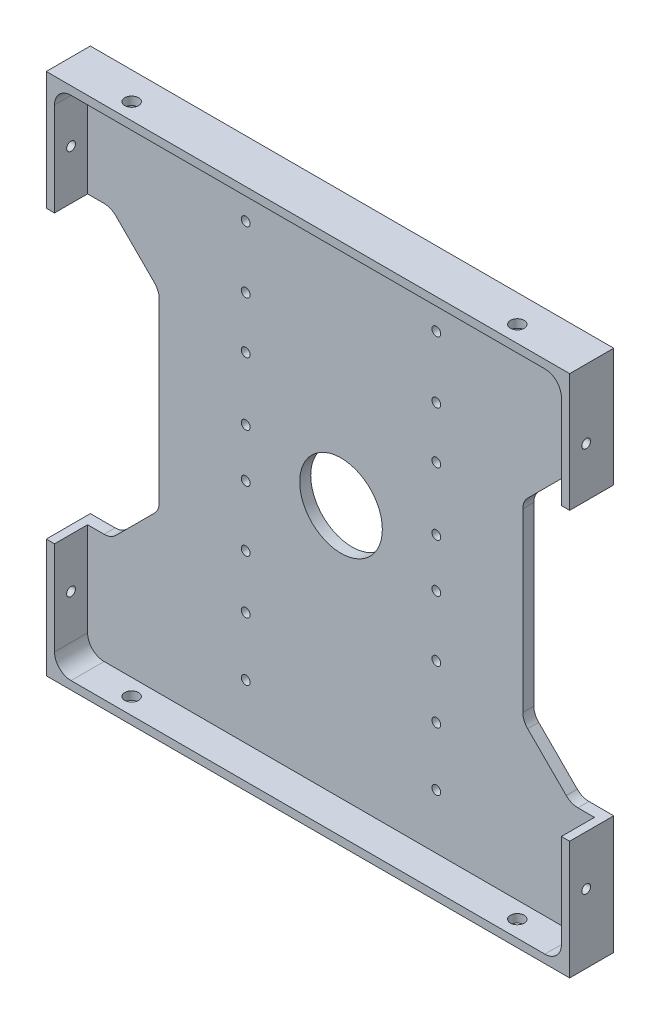
from build123d import *

# Parameters (mm, degrees)
SKETCH1_W                       = 96
SKETCH1_H                       = 96
BOSS_EXTRUDE1_DEPTH             = 8
SKETCH2_W                       = 92
SKETCH2_H                       = 92
COMPONENT_PLATFORM_DEPTH        = 6
CABLE_SLOTS_DEPTH               = 6
SKETCH4_R                       = 7.5
CENTER_MASS_CUT_DEPTH           = 6
INNER_CORNER_FILLETS_R          = 3
TAP_DRILL_FOR_M3X0_5_TAP4_D     = 2.5
TAP_DRILL_FOR_M3X0_5_TAP4_DEPTH = 2
TAP_DRILL_FOR_M2X0_4_TAP2_D     = 1.6
TAP_DRILL_FOR_M2X0_4_TAP1_D     = 1.6
TAP_DRILL_FOR_M2X0_4_TAP1_DEPTH = 2
CUT_EXTRUDE1_START              = -8
SKETCH28_OUTSIDE_W              = 125.2
SKETCH28_OUTSIDE_H              = 125.2
SKETCH28_OUTSIDE_W_2            = 95
SKETCH28_OUTSIDE_H_2            = 95
CUT_EXTRUDE1_DEPTH              = 8


with BuildPart() as part:
    # Sketch1 → Boss-Extrude1 (new body)
    with BuildSketch(Plane.XY):
        Rectangle(SKETCH1_W, SKETCH1_H)
    extrude(amount=BOSS_EXTRUDE1_DEPTH)

    # Sketch2 → Component Platform (cut)
    with BuildSketch(Plane.XY.offset(8)):
        Rectangle(SKETCH2_W, SKETCH2_H)
    extrude(amount=-COMPONENT_PLATFORM_DEPTH, mode=Mode.SUBTRACT)

    # Sketch3 → Cable Slots (cut, symmetric)
    with BuildSketch(Plane.XY.offset(2)):
        with BuildLine():
            Line((-40.878679656, -25.121320344), (-33.878679656, -18.121320344))
            ThreePointArc((-33.878679656, -18.121320344), (-33.228361402, -17.148050297), (-33, -16))
            Line((-33, -16), (-33, 16))
            ThreePointArc((-33, 16), (-33.228361402, 17.148050297), (-33.878679656, 18.121320344))
            Line((-33.878679656, 18.121320344), (-40.878679656, 25.121320344))
            ThreePointArc((-40.878679656, 25.121320344), (-41.851949703, 25.771638598), (-43, 26))
            Line((-43, 26), (-48, 26))
            Line((-48, 26), (-48, -26))
            Line((-48, -26), (-43, -26))
            ThreePointArc((-43, -26), (-41.851949703, -25.771638598), (-40.878679656, -25.121320344))
        make_face()
        with BuildLine():
            Line((48, -26), (48, 26))
            Line((48, 26), (43, 26))
            ThreePointArc((43, 26), (41.851949703, 25.771638598), (40.878679656, 25.121320344))
            Line((40.878679656, 25.121320344), (33.878679656, 18.121320344))
            ThreePointArc((33.878679656, 18.121320344), (33.228361402, 17.148050297), (33, 16))
            Line((33, 16), (33, -16))
            ThreePointArc((33, -16), (33.228361402, -17.148050297), (33.878679656, -18.121320344))
            Line((33.878679656, -18.121320344), (40.878679656, -25.121320344))
            ThreePointArc((40.878679656, -25.121320344), (41.851949703, -25.771638598), (43, -26))
            Line((43, -26), (48, -26))
        make_face()
    extrude(amount=CABLE_SLOTS_DEPTH, both=True, mode=Mode.SUBTRACT)

    # Sketch4 → Center Mass Cut (cut)
    with BuildSketch(Plane.XY.offset(2)):
        Circle(SKETCH4_R)
    extrude(amount=-CENTER_MASS_CUT_DEPTH, mode=Mode.SUBTRACT)

    # Inner Corner Fillets
    inner_corner_fillets_edges = [part.edges().sort_by_distance(p)[0] for p in [
        (-46, -46, 5),
        (-46, 46, 5),
        (46, 46, 5),
        (46, -46, 5),
    ]]
    fillet(inner_corner_fillets_edges, radius=INNER_CORNER_FILLETS_R)

    # Tap Drill for M3x0.5 Tap4
    with Locations(Plane(origin=(0, -48, 0), x_dir=(-1, 0, 0), z_dir=(0, -1, 0))):
        with Locations((35, -5), (-35, -5)):
            tap_drill_for_m3x0_5_tap4 = Hole(TAP_DRILL_FOR_M3X0_5_TAP4_D / 2, depth=TAP_DRILL_FOR_M3X0_5_TAP4_DEPTH)

    # Mirror2: Tap Drill for M3x0.5 Tap4 across plane
    add(tap_drill_for_m3x0_5_tap4.mirror(Plane(origin=(0, 0, 0), x_dir=(0, 0, 1), z_dir=(0, -1, 0))), mode=Mode.SUBTRACT)

    # Tap Drill for M2x0.4 Tap2 (through all)
    with Locations(Plane.XY.offset(2)):
        with Locations((-17.3, 36.05), (-17.3, 24.85), (-17.3, 15.45), (-17.3, 4.05), (17.3, 4.05), (17.3, 15.45), (17.3, 24.85), (17.3, 36.05), (17.3, -4.75), (17.3, -15.75), (17.3, -25.45), (17.3, -36.05), (-17.3, -4.75), (-17.3, -15.75), (-17.3, -25.45), (-17.3, -36.05)):
            Hole(TAP_DRILL_FOR_M2X0_4_TAP2_D / 2)

    # Tap Drill for M2x0.4 Tap1
    with Locations(Plane(origin=(48, 0, 0), x_dir=(0, 0, -1), z_dir=(1, 0, 0))):
        with Locations((-5, -35), (-5, 35)):
            tap_drill_for_m2x0_4_tap1 = Hole(TAP_DRILL_FOR_M2X0_4_TAP1_D / 2, depth=TAP_DRILL_FOR_M2X0_4_TAP1_DEPTH)

    # Mirror3: Tap Drill for M2x0.4 Tap1 across plane
    add(tap_drill_for_m2x0_4_tap1.mirror(Plane(origin=(0, 0, 0), x_dir=(0, 0, 1), z_dir=(1, 0, 0))), mode=Mode.SUBTRACT)

    # Sketch28 outside → Cut-Extrude1 (cut)
    with BuildSketch(Plane(origin=(0, 0, 0), x_dir=(-1, 0, 0), z_dir=(0, 0, -1)).offset(CUT_EXTRUDE1_START)):
        Rectangle(SKETCH28_OUTSIDE_W, SKETCH28_OUTSIDE_H)
        Rectangle(SKETCH28_OUTSIDE_W_2, SKETCH28_OUTSIDE_H_2, mode=Mode.SUBTRACT)
    extrude(amount=CUT_EXTRUDE1_DEPTH, mode=Mode.SUBTRACT)


solid = part.part
